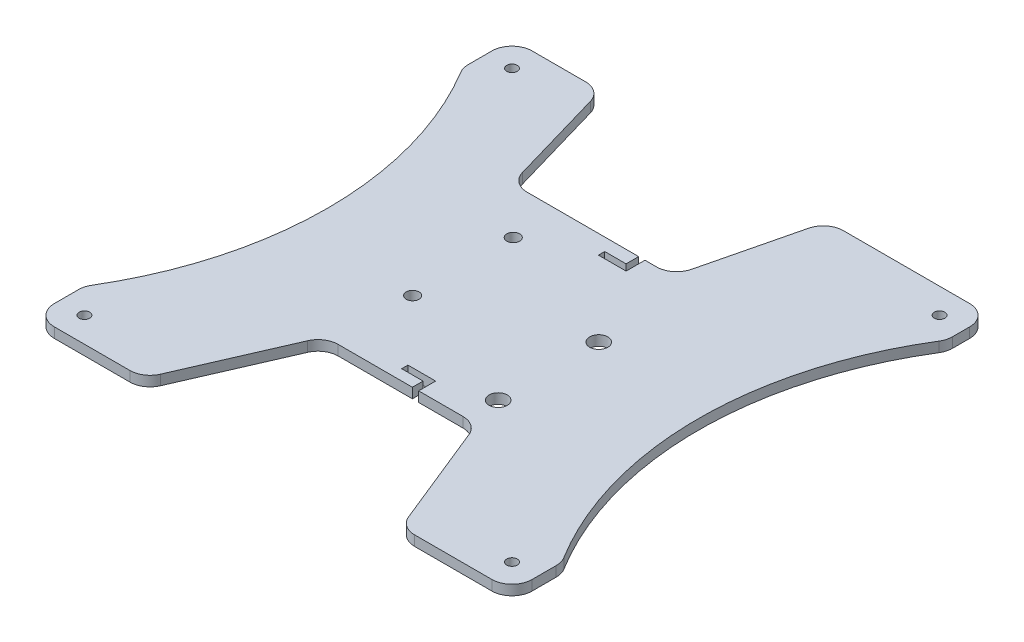
from build123d import *

# Parameters (mm, degrees)
SKETCH1_W               = 190
SKETCH1_H               = 190
BASE_DEPTH              = 4
SKETCH1_5_R             = 2.1
CUT_EXTRUDE2_DEPTH      = 4
MIRROR2_COPY_1_SKETCH_R = 2.1
MIRROR2_COPY_1_DEPTH    = 4
SKETCH2_R               = 2.55
SKETCH2_R_2             = 3.6
HOLES_DEPTH             = 135.40982107
CUT_EXTRUDE4_DEPTH      = 4
CUT_EXTRUDE5_DEPTH      = 4
CUT_EXTRUDE6_DEPTH      = 4
FILLET1_R               = 8
CUT_EXTRUDE7_DEPTH      = 4


with BuildPart() as part:
    # Sketch1 → base (new body)
    with BuildSketch(Plane(origin=(0, 0, 0), x_dir=(1, 0, 0), z_dir=(0, 1, 0))):
        Rectangle(SKETCH1_W, SKETCH1_H)
    extrude(amount=-BASE_DEPTH)

    # Sketch1_5 → Cut-Extrude2 (cut)
    with BuildSketch(Plane(origin=(0, 0, 0), x_dir=(1, 0, 0), z_dir=(0, 1, 0))):
        with Locations((-85, 85)):
            Circle(SKETCH1_5_R)
    cut_extrude2 = extrude(amount=-CUT_EXTRUDE2_DEPTH, mode=Mode.SUBTRACT)

    # Mirror1: Cut-Extrude2 across plane
    add(cut_extrude2.mirror(Plane(origin=(0, 0, 0), x_dir=(0, 0, 1), z_dir=(1, 0, 0))), mode=Mode.SUBTRACT)

    # Mirror2: Cut-Extrude2 across plane
    add(cut_extrude2.mirror(Plane.XY), mode=Mode.SUBTRACT)

    # Mirror2 copy 1 sketch → Mirror2 copy 1 (cut)
    with BuildSketch(Plane(origin=(0, 0, 0), x_dir=(-1, 0, 0), z_dir=(0, 1, 0))):
        with Locations((-85, 85)):
            Circle(MIRROR2_COPY_1_SKETCH_R)
    extrude(amount=-MIRROR2_COPY_1_DEPTH, mode=Mode.SUBTRACT)

    # Sketch2 → holes (cut, through all)
    with BuildSketch(Plane(origin=(0, 0, 0), x_dir=(1, 0, 0), z_dir=(0, 1, 0))):
        with Locations((-26.5, 27)):
            Circle(SKETCH2_R)
        with Locations((-26.5, -13)):
            Circle(SKETCH2_R)
        with Locations((26.5, -32)):
            Circle(SKETCH2_R_2)
        with Locations((26.5, 8)):
            Circle(SKETCH2_R_2)
    extrude(amount=-HOLES_DEPTH, mode=Mode.SUBTRACT)

    # Sketch3 → Cut-Extrude4 (cut)
    with BuildSketch(Plane(origin=(0, 0, 0), x_dir=(1, 0, 0), z_dir=(0, 1, 0))):
        Polygon((-45.366645318, 45.366645318), (18.398695046, 45.366645318), (30.496467131, 95), (-59.732749669, 95), align=None)
        Polygon((-51.667568279, -95), (50.911457524, -95), (30.496467131, -44.610534563), (-29.740356375, -44.610534563), align=None)
    extrude(amount=-CUT_EXTRUDE4_DEPTH, mode=Mode.SUBTRACT)

    # Sketch5 → Cut-Extrude5 (cut)
    with BuildSketch(Plane(origin=(0, 0, 0), x_dir=(1, 0, 0), z_dir=(0, 1, 0))):
        with BuildLine():
            Line((-95, 75.359038612), (-95, -75.107001693))
            ThreePointArc((-95, -75.107001693), (-73.504234295, 0.126018459), (-95, 75.359038612))
        make_face()
    extrude(amount=-CUT_EXTRUDE5_DEPTH, mode=Mode.SUBTRACT)

    # Sketch5_3 → Cut-Extrude6 (cut)
    with BuildSketch(Plane(origin=(0, 0, 0), x_dir=(1, 0, 0), z_dir=(0, 1, 0))):
        with BuildLine():
            Line((-95, 75.359038612), (-95, -75.107001693))
            ThreePointArc((-95, -75.107001693), (-73.504234295, 0.126018459), (-95, 75.359038612))
        make_face()
        with BuildLine():
            Line((95, -75.107001693), (95, 77.879407796))
            ThreePointArc((95, 77.879407796), (72.661894517, 1.386203051), (95, -75.107001693))
        make_face()
    extrude(amount=-CUT_EXTRUDE6_DEPTH, mode=Mode.SUBTRACT)

    # Fillet1
    fillet1_edges = [part.edges().sort_by_distance(p)[0] for p in [
        (-95, -2, 75.107001693),
        (-95, -2, 95),
        (-51.667568279, -2, 95),
        (-29.740356375, -2, 44.610534563),
        (30.496467131, -2, 44.610534563),
        (50.911457524, -2, 95),
        (95, -2, 95),
        (95, -2, 75.107001693),
        (95, -2, -77.879407796),
        (95, -2, -95),
        (30.496467131, -2, -95),
        (18.398695046, -2, -45.366645318),
        (-45.366645318, -2, -45.366645318),
        (-59.732749669, -2, -95),
        (-95, -2, -75.359038612),
        (-95, -2, -95),
    ]]
    fillet(fillet1_edges, radius=FILLET1_R)

    # Sketch7 → Cut-Extrude7 (cut)
    with BuildSketch(Plane(origin=(0, 0, 0), x_dir=(1, 0, 0), z_dir=(0, 1, 0))):
        Polygon((5, 45.366645318), (5, 40.366645318), (-3.5, 40.366645318), (-3.5, 37.866645318), (7.5, 37.866645318), (7.5, 45.366645318), align=None)
    cut_extrude7 = extrude(amount=-CUT_EXTRUDE7_DEPTH, mode=Mode.SUBTRACT)

    # Mirror3: Cut-Extrude7 across plane
    add(cut_extrude7.mirror(Plane.XY), mode=Mode.SUBTRACT)


solid = part.part
